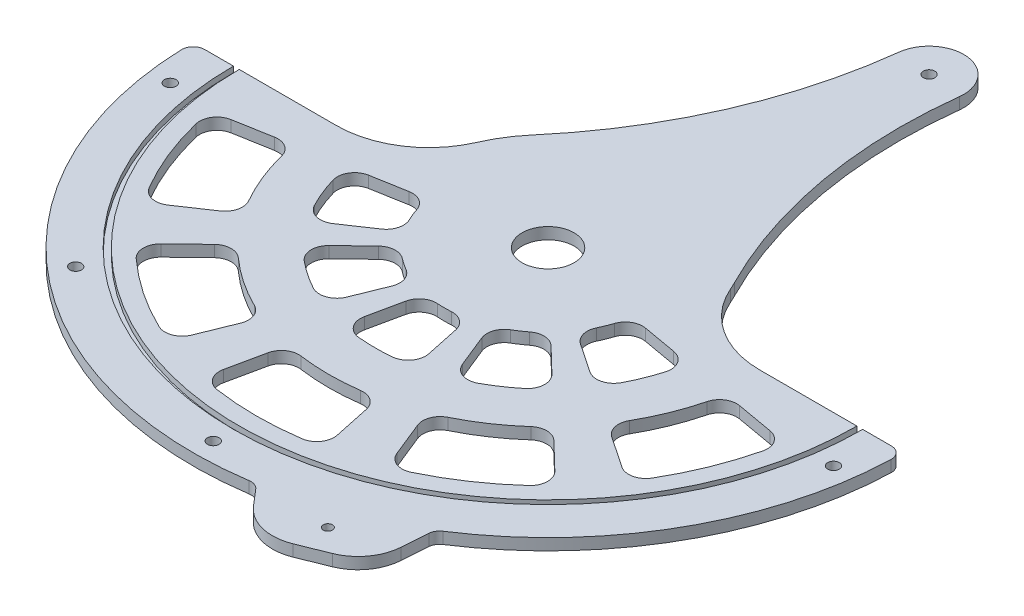
from build123d import *

# Parameters (mm, degrees)
BOSS_EXTRUDE1_DEPTH = 3.175
CUT_EXTRUDE1_DEPTH  = 7.35
CUT_EXTRUDE2_DEPTH  = 3.175
BOSS_EXTRUDE2_DEPTH = 3.175
SKETCH6_R           = 14.2875
CUT_EXTRUDE3_DEPTH  = 7.35
BOSS_EXTRUDE3_DEPTH = 6.35
SKETCH8_R           = 2.54
CUT_EXTRUDE4_DEPTH  = 7.35
SKETCH9_R           = 3.175
CUT_EXTRUDE5_DEPTH  = 7.35
FILLET1_R           = 25.4
FILLET2_R           = 9.525
FILLET4_R           = 6.35
FILLET3_R           = 50.8
SKETCH10_R          = 3.175
BOSS_EXTRUDE4_DEPTH = 6.35


with BuildPart() as part:
    # Sketch1 → Boss-Extrude1 (new body, symmetric)
    with BuildSketch(Plane(origin=(0, 0, 0), x_dir=(1, 0, 0), z_dir=(0, 1, 0))):
        with BuildLine():
            Line((76.2, 0), (173.0375, 0))
            ThreePointArc((173.0375, 0), (0, -173.0375), (-173.0375, 0))
            Line((-173.0375, 0), (-76.2, 0))
            ThreePointArc((-76.2, 0), (0, 76.2), (76.2, 0))
        make_face()
    extrude(amount=BOSS_EXTRUDE1_DEPTH, both=True)

    # Sketch2 → Cut-Extrude1 (cut, through all)
    with BuildSketch(Plane(origin=(0, 3.175, 0), x_dir=(1, 0, 0), z_dir=(0, 1, 0))):
        with BuildLine():
            Line((-78.965828786, -53.263124056), (-47.379497272, -31.957874433))
            ThreePointArc((-47.379497272, -31.957874433), (-52.988557288, -21.408766814), (-56.281763085, -9.923993354))
            Line((-56.281763085, -9.923993354), (-93.802938474, -16.539988923))
            ThreePointArc((-93.802938474, -16.539988923), (-88.314262147, -35.681278023), (-78.965828786, -53.263124056))
        make_face()
        with BuildLine():
            Line((-60.063484672, -148.662341282), (-45.196285496, -111.864732053))
            ThreePointArc((-45.196285496, -111.864732053), (-67.466623804, -100.023383129), (-86.788346911, -83.810532396))
            Line((-86.788346911, -83.810532396), (-115.337145237, -111.379786473))
            ThreePointArc((-115.337145237, -111.379786473), (-89.65959216, -132.92581179), (-60.063484672, -148.662341282))
        make_face()
        with BuildLine():
            Line((-35.681278023, -88.314262147), (-21.408766814, -52.988557288))
            ThreePointArc((-21.408766814, -52.988557288), (-31.957874433, -47.379497272), (-41.110269589, -39.699725872))
            Line((-41.110269589, -39.699725872), (-68.517115982, -66.166209786))
            ThreePointArc((-68.517115982, -66.166209786), (-53.263124056, -78.965828786), (-35.681278023, -88.314262147))
        make_face()
        with BuildLine():
            Line((-132.92581179, -89.65959216), (-100.023383129, -67.466623804))
            ThreePointArc((-100.023383129, -67.466623804), (-111.864732053, -45.196285496), (-118.817055401, -20.950652636))
            Line((-118.817055401, -20.950652636), (-157.901613099, -27.842314687))
            ThreePointArc((-157.901613099, -27.842314687), (-148.662341282, -60.063484672), (-132.92581179, -89.65959216))
        make_face()
        with BuildLine():
            Line((33.336040726, -156.833740933), (25.084545497, -118.013508029))
            ThreePointArc((25.084545497, -118.013508029), (0, -120.65), (-25.084545497, -118.013508029))
            Line((-25.084545497, -118.013508029), (-33.336040726, -156.833740933))
            ThreePointArc((-33.336040726, -156.833740933), (0, -160.3375), (33.336040726, -156.833740933))
        make_face()
        with BuildLine():
            Line((19.80358855, -93.16855897), (11.88215313, -55.901135382))
            ThreePointArc((11.88215313, -55.901135382), (0, -57.15), (-11.88215313, -55.901135382))
            Line((-11.88215313, -55.901135382), (-19.80358855, -93.16855897))
            ThreePointArc((-19.80358855, -93.16855897), (0, -95.25), (19.80358855, -93.16855897))
        make_face()
        with BuildLine():
            Line((115.337145237, -111.379786473), (86.788346911, -83.810532396))
            ThreePointArc((86.788346911, -83.810532396), (67.466623804, -100.023383129), (45.196285496, -111.864732053))
            Line((45.196285496, -111.864732053), (60.063484672, -148.662341282))
            ThreePointArc((60.063484672, -148.662341282), (89.65959216, -132.92581179), (115.337145237, -111.379786473))
        make_face()
        with BuildLine():
            Line((68.517115982, -66.166209786), (41.110269589, -39.699725872))
            ThreePointArc((41.110269589, -39.699725872), (31.957874433, -47.379497272), (21.408766814, -52.988557288))
            Line((21.408766814, -52.988557288), (35.681278023, -88.314262147))
            ThreePointArc((35.681278023, -88.314262147), (53.263124056, -78.965828786), (68.517115982, -66.166209786))
        make_face()
        with BuildLine():
            Line((157.901613099, -27.842314687), (118.817055401, -20.950652636))
            ThreePointArc((118.817055401, -20.950652636), (111.864732053, -45.196285496), (100.023383129, -67.466623804))
            Line((100.023383129, -67.466623804), (132.92581179, -89.65959216))
            ThreePointArc((132.92581179, -89.65959216), (148.662341282, -60.063484672), (157.901613099, -27.842314687))
        make_face()
        with BuildLine():
            Line((93.802938474, -16.539988923), (56.281763085, -9.923993354))
            ThreePointArc((56.281763085, -9.923993354), (52.988557288, -21.408766814), (47.379497272, -31.957874433))
            Line((47.379497272, -31.957874433), (78.965828786, -53.263124056))
            ThreePointArc((78.965828786, -53.263124056), (88.314262147, -35.681278023), (93.802938474, -16.539988923))
        make_face()
    extrude(amount=-CUT_EXTRUDE1_DEPTH, mode=Mode.SUBTRACT)

    # Sketch5 → Cut-Extrude2 (cut)
    with BuildSketch(Plane(origin=(0, 3.175, 0), x_dir=(1, 0, 0), z_dir=(0, 1, 0))):
        with BuildLine():
            Line((169.8625, 0), (173.0375, 0))
            ThreePointArc((173.0375, 0), (0, -173.0375), (-173.0375, 0))
            Line((-173.0375, 0), (-169.8625, 0))
            ThreePointArc((-169.8625, 0), (0, -169.8625), (169.8625, 0))
        make_face()
    extrude(amount=-CUT_EXTRUDE2_DEPTH, mode=Mode.SUBTRACT)

    # Sketch4 → Boss-Extrude2 (add, symmetric)
    with BuildSketch(Plane(origin=(0, 0, 0), x_dir=(1, 0, 0), z_dir=(0, 1, 0))):
        with BuildLine():
            Line((173.0375, 0), (195.2625, 0))
            ThreePointArc((195.2625, 0), (0, -195.2625), (-195.2625, 0))
            Line((-195.2625, 0), (-173.0375, 0))
            ThreePointArc((-173.0375, 0), (0, -173.0375), (173.0375, 0))
        make_face()
    extrude(amount=BOSS_EXTRUDE2_DEPTH, both=True)

    # Sketch6 → Cut-Extrude3 (cut, through all)
    with BuildSketch(Plane(origin=(0, 3.175, 0), x_dir=(1, 0, 0), z_dir=(0, 1, 0))):
        Circle(SKETCH6_R)
    extrude(amount=-CUT_EXTRUDE3_DEPTH, mode=Mode.SUBTRACT)

    # Sketch7 → Boss-Extrude3 (add, through all)
    with BuildSketch(Plane(origin=(0, 3.175, 0), x_dir=(1, 0, 0), z_dir=(0, 1, 0))):
        Polygon((32.206866836, -192.588062026), (53.968732111, -217.988062026), (101.069671923, -198.95804708), (103.466206527, -165.596461355), align=None)
    extrude(amount=-BOSS_EXTRUDE3_DEPTH)

    # Sketch8 → Cut-Extrude4 (cut, through all)
    with BuildSketch(Plane(origin=(0, 3.175, 0), x_dir=(-1, 0, 0), z_dir=(0, 1, 0))):
        with Locations((-72.677869349, 193.782658122)):
            Circle(SKETCH8_R)
    extrude(amount=-CUT_EXTRUDE4_DEPTH, mode=Mode.SUBTRACT)

    # Sketch9 → Cut-Extrude5 (cut, through all)
    with BuildSketch(Plane(origin=(0, 3.175, 0), x_dir=(1, 0, 0), z_dir=(0, 1, 0))):
        with Locations((-182.389864028, -25.4)):
            Circle(SKETCH9_R)
        with Locations((-120.900398056, -138.903982124)):
            Circle(SKETCH9_R)
        with Locations((0, -184.15)):
            Circle(SKETCH9_R)
        with Locations((182.389864028, -25.4)):
            Circle(SKETCH9_R)
    extrude(amount=-CUT_EXTRUDE5_DEPTH, mode=Mode.SUBTRACT)

    # Fillet1
    fillet1_edges = [part.edges().sort_by_distance(p)[0] for p in [
        (53.968732111, 0, 217.988062026),
        (101.069671923, 0, 198.95804708),
    ]]
    fillet(fillet1_edges, radius=FILLET1_R)

    # Fillet2
    fillet2_edges = [part.edges().sort_by_distance(p)[0] for p in [
        (-35.681278023, 0, 88.314262147),
        (-68.517115982, 0, 66.166209786),
        (-41.110269589, 0, 39.699725872),
        (-21.408766814, 0, 52.988557288),
        (33.336040726, 0, 156.833740933),
        (-33.336040726, 0, 156.833740933),
        (-25.084545497, 0, 118.013508029),
        (25.084545497, 0, 118.013508029),
        (-132.92581179, 0, 89.65959216),
        (-157.901613099, 0, 27.842314687),
        (-118.817055401, 0, 20.950652636),
        (-100.023383129, 0, 67.466623804),
        (19.80358855, 0, 93.16855897),
        (-19.80358855, 0, 93.16855897),
        (-11.88215313, 0, 55.901135382),
        (11.88215313, 0, 55.901135382),
        (115.337145237, 0, 111.379786473),
        (60.063484672, 0, 148.662341282),
        (45.196285496, 0, 111.864732053),
        (86.788346911, 0, 83.810532396),
        (93.802938474, 0, 16.539988923),
        (78.965828786, 0, 53.263124056),
        (47.379497272, 0, 31.957874433),
        (56.281763085, 0, 9.923993354),
        (157.901613099, 0, 27.842314687),
        (132.92581179, 0, 89.65959216),
        (100.023383129, 0, 67.466623804),
        (118.817055401, 0, 20.950652636),
        (68.517115982, 0, 66.166209786),
        (35.681278023, 0, 88.314262147),
        (21.408766814, 0, 52.988557288),
        (41.110269589, 0, 39.699725872),
        (-78.965828786, 0, 53.263124056),
        (-93.802938474, 0, 16.539988923),
        (-56.281763085, 0, 9.923993354),
        (-47.379497272, 0, 31.957874433),
        (-60.063484672, 0, 148.662341282),
        (-115.337145237, 0, 111.379786473),
        (-86.788346911, 0, 83.810532396),
        (-45.196285496, 0, 111.864732053),
    ]]
    fillet(fillet2_edges, radius=FILLET2_R)

    # Fillet4
    fillet4_edges = [part.edges().sort_by_distance(p)[0] for p in [
        (-195.2625, 0, 0),
        (195.2625, 0, 0),
        (32.206866836, 0, 192.588062026),
        (103.466206527, 0, 165.596461355),
    ]]
    fillet(fillet4_edges, radius=FILLET4_R)

    # Fillet3
    fillet3_edges = [part.edges().sort_by_distance(p)[0] for p in [
        (-76.2, 0, 0),
        (76.2, 0, 0),
    ]]
    fillet(fillet3_edges, radius=FILLET3_R)

    # Sketch10 → Boss-Extrude4 (add, through all)
    with BuildSketch(Plane(origin=(0, 3.175, 0), x_dir=(1, 0, 0), z_dir=(0, 1, 0))):
        with BuildLine():
            ThreePointArc((41.142321921, 185.080577729), (43.382996969, 107.81939227), (67.928946778, 34.526774967))
            ThreePointArc((67.928946778, 34.526774967), (8.977730657, 75.669282752), (-57.964006259, 49.463258873))
            ThreePointArc((-57.964006259, 49.463258873), (-16.94944122, 114.977483636), (3.307678079, 189.569422271))
            ThreePointArc((3.307678079, 189.569422271), (24.469422271, 206.242321921), (41.142321921, 185.080577729))
        make_face()
        with Locations((22.225, 187.325)):
            Circle(SKETCH10_R, mode=Mode.SUBTRACT)
    extrude(amount=-BOSS_EXTRUDE4_DEPTH)


solid = part.part
